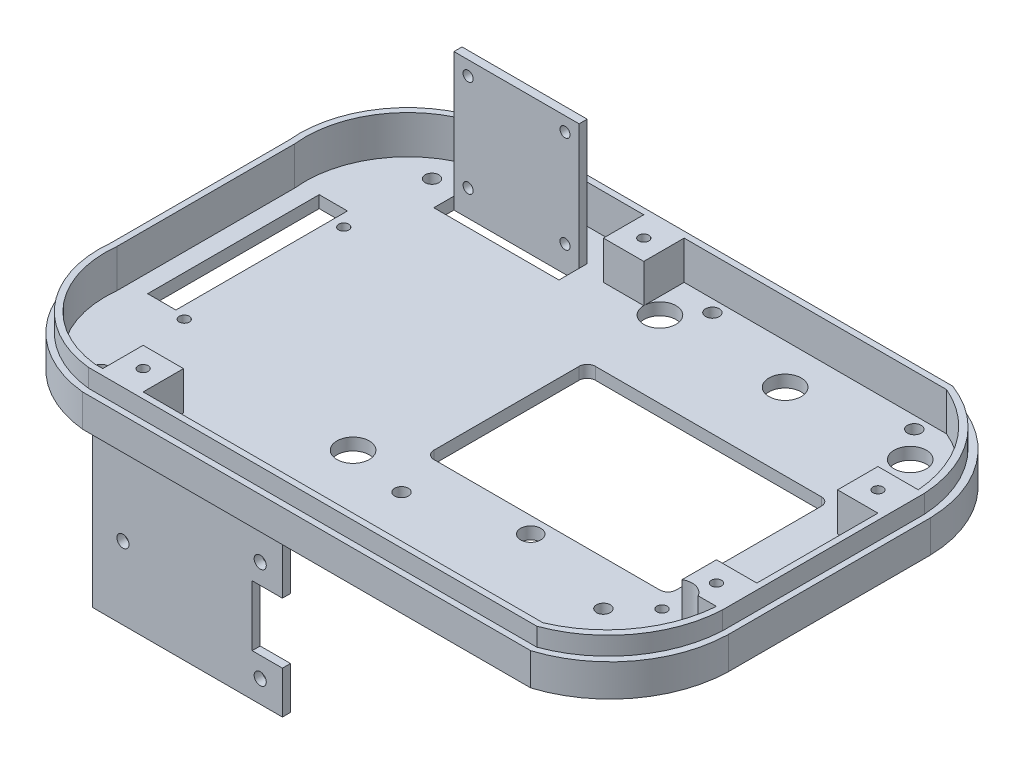
from build123d import *

# Parameters (mm, degrees)
BOSS_EXTRUDE1_DEPTH            = 86.5
SKETCH2_W                      = 200.99999999999994
SKETCH2_H                      = 100.00000000000001
CUT_EXTRUDE1_DEPTH             = 35
CUT_EXTRUDE2_DEPTH             = 49.5
CUT_EXTRUDE3_DEPTH             = 48.5
CUT_EXTRUDE4_DEPTH             = 49.5
SKETCH12_W                     = 54.00000000000001
SKETCH12_H                     = 20
CUT_EXTRUDE5_DEPTH             = 3
SKETCH19_W                     = 207
SKETCH19_H                     = 106
SKETCH19_W_2                   = 204
SKETCH19_H_2                   = 103
CUT_EXTRUDE10_DEPTH            = 30
SKETCH20_W                     = 204
SKETCH20_H                     = 103
SKETCH20_W_2                   = 200.99999999999994
SKETCH20_H_2                   = 100.00000000000001
CUT_EXTRUDE11_DEPTH            = 25.5
BOSS_EXTRUDE4_DEPTH            = 9.5
BOSS_EXTRUDE6_DEPTH            = 9.5
CUT_EXTRUDE20_DEPTH            = 126.99007897449711
FILLET2_R                      = 2
M3_CLEARANCE_HOLE1_D           = 3.4
CUT_EXTRUDE25_DEPTH            = 126.99007897449711
BOSS_EXTRUDE7_DEPTH            = 3
BOSS_EXTRUDE8_DEPTH            = 5
BOSS_EXTRUDE9_DEPTH            = 9.5
SKETCH71_W                     = 21.000000000000057
SKETCH71_H                     = 27.99999999999999
CUT_EXTRUDE26_DEPTH            = 126.99007897449708
BOSS_EXTRUDE10_DEPTH           = 3
BOSS_EXTRUDE11_DEPTH           = 5
BOSS_EXTRUDE12_DEPTH           = 9.5
CUT_EXTRUDE28_DEPTH            = 126.99007897449708
CUT_EXTRUDE28_DEPTH_BACK       = 126.99007897449708
SKETCH76_W                     = 54.99999999999997
SKETCH76_H                     = 15
BOSS_EXTRUDE16_START           = -2
BOSS_EXTRUDE16_DEPTH           = 2
BOSS_EXTRUDE19_DEPTH           = 59
CUT_EXTRUDE31_DEPTH            = 131.3926761746994
SKETCH102_W                    = 10.000000000000004
SKETCH102_H                    = 10.000000000000007
BOSS_EXTRUDE22_DEPTH           = 9.5
CUT_EXTRUDE33_DEPTH            = 53
CUT_EXTRUDE33_DEPTH_BACK       = 119.30000000000004
SKETCH108_W                    = 60.521320783260805
SKETCH108_H                    = 107.41941148005114
M3X0_5_TAPPED_HOLE6_D          = 2.5
M3X0_5_TAPPED_HOLE6_DEPTH      = 2
M3X0_5_TAPPED_HOLE6_TIP        = 0.7510757737844503
BOSS_EXTRUDE26_DEPTH           = 3
BOSS_EXTRUDE28_DEPTH           = 9.5
CUT_EXTRUDE39_DEPTH            = 117.66833332142879
CUT_EXTRUDE39_DEPTH_BACK       = 22.000000000000007
SKETCH128_W                    = 25.45272173772948
SKETCH128_H                    = 30.999999999999996
CUT_EXTRUDE40_DEPTH            = 26.000000000000018
CUT_EXTRUDE40_DEPTH_BACK       = 24.000000000000007
BOSS_EXTRUDE29_START           = -3
BOSS_EXTRUDE29_DEPTH           = 3
BOSS_EXTRUDE30_START           = -3
BOSS_EXTRUDE30_DEPTH           = 3
M3X0_5_TAPPED_HOLE8_D          = 2.5
M3X0_5_TAPPED_HOLE8_DEPTH      = 2
M3X0_5_TAPPED_HOLE8_TIP        = 0.7510757737844503
SKETCH134_W                    = 10
SKETCH134_H                    = 10.000000000000007
BOSS_EXTRUDE31_DEPTH           = 9.5
BOSS_EXTRUDE33_DEPTH           = 9.5
BOSS_EXTRUDE35_DEPTH           = 5
CUT_EXTRUDE41_START            = -9.5
SKETCH140_W                    = 9.999999999999996
SKETCH140_H                    = 10.000000000000007
SKETCH140_W_2                  = 10
CUT_EXTRUDE41_DEPTH            = 9.5
SKETCH142_W                    = 10
SKETCH142_H                    = 10.000000000000007
BOSS_EXTRUDE37_DEPTH           = 9.5
BOSS_EXTRUDE38_DEPTH           = 57
BOSS_EXTRUDE40_DEPTH           = 31
F_2_5MM_DOWEL_HOLE1_D          = 2.5
F_2_5MM_DOWEL_HOLE1_DEPTH      = 4
F_2_5MM_DOWEL_HOLE1_TIP        = 0.7510757737844503
SKETCH148_W                    = 31
SKETCH148_H                    = 5
CUT_EXTRUDE42_DEPTH            = 31
F_3_0MM_DOWEL_HOLE1_D          = 3
F_3_0MM_DOWEL_HOLE1_DEPTH      = 4
F_3_0MM_DOWEL_HOLE1_TIP        = 0.9012909285413404
CUT_EXTRUDE43_DEPTH            = 57
M3X0_5_TAPPED_HOLE9_D          = 2.5
M3X0_5_TAPPED_HOLE9_DEPTH      = 2
M3X0_5_TAPPED_HOLE9_TIP        = 0.7510757737844503
CUT_EXTRUDE44_DEPTH            = 57
M3_CLEARANCE_HOLE2_D           = 3.4
F_8_0MM_DOWEL_HOLE1_D          = 8
F_8_0MM_DOWEL_HOLE2_AT_2_COUNT = 2
F_8_0MM_DOWEL_HOLE2_AT_2_PITCH = 79.99999999999999
SKETCH165_R                    = 4.000000000000005
CUT_EXTRUDE45_DEPTH            = 10
F_5_0MM_DOWEL_HOLE1_D          = 5
F_5_0MM_DOWEL_HOLE1_DEPTH      = 12.5
F_5_0MM_DOWEL_HOLE1_TIP        = 1.5021515475689007


with BuildPart() as part:
    # Sketch1 → Boss-Extrude1 (new body)
    with BuildSketch(Plane(origin=(0, 0, 0), x_dir=(1, 0, 0), z_dir=(0, 1, 0))):
        Polygon((-103.49999999999997, 52.99999999999999), (103.50000000000003, 52.99999999999999), (103.50000000000006, -53.00000000000001), (-103.49999999999997, -53.00000000000001), align=None)
    extrude(amount=BOSS_EXTRUDE1_DEPTH)

    # Sketch2 → Cut-Extrude1 (cut)
    with BuildSketch(Plane(origin=(0, 86.5, 0), x_dir=(1, 0, 0), z_dir=(0, 1, 0))):
        Rectangle(SKETCH2_W, SKETCH2_H)
    extrude(amount=-CUT_EXTRUDE1_DEPTH, mode=Mode.SUBTRACT)

    # Sketch4 → Cut-Extrude2 (cut)
    with BuildSketch(Plane(origin=(0, 51.49999999999999, 0), x_dir=(1, 0, 0), z_dir=(0, 1, 0))):
        Polygon((-100.49999999999997, 50), (-53.50000000000001, 50), (-53.49999999999999, -50), (-100.49999999999996, -50), align=None)
    extrude(amount=-CUT_EXTRUDE2_DEPTH, mode=Mode.SUBTRACT)

    # Sketch8 → Cut-Extrude3 (cut)
    with BuildSketch(Plane.XZ):
        Polygon((-43.49999999999997, 53.00000000000001), (103.50000000000007, 53.00000000000001), (103.50000000000004, -52.99999999999999), (-43.49999999999996, -52.99999999999999), align=None)
    extrude(amount=-CUT_EXTRUDE3_DEPTH, mode=Mode.SUBTRACT)

    # Sketch11 → Cut-Extrude4 (cut)
    with BuildSketch(Plane(origin=(0, 51.49999999999999, 0), x_dir=(1, 0, 0), z_dir=(0, 1, 0))):
        Polygon((-53.50000000000001, 50), (-48.50000000000001, 50), (-48.49999999999999, -50), (-53.50000000000001, -50), align=None)
    extrude(amount=-CUT_EXTRUDE4_DEPTH, mode=Mode.SUBTRACT)

    # Sketch12 → Cut-Extrude5 (cut)
    with BuildSketch(Plane(origin=(0, 0, -52.99999999999999), x_dir=(-1, 0, 0), z_dir=(0, 0, -1))):
        with Locations((73.49999999999997, 13)):
            Rectangle(SKETCH12_W, SKETCH12_H)
    extrude(amount=-CUT_EXTRUDE5_DEPTH, mode=Mode.SUBTRACT)

    # Sketch19 → Cut-Extrude10 (cut)
    with BuildSketch(Plane(origin=(0, 86.5, 0), x_dir=(1, 0, 0), z_dir=(0, 1, 0))):
        Rectangle(SKETCH19_W, SKETCH19_H)
        Rectangle(SKETCH19_W_2, SKETCH19_H_2, mode=Mode.SUBTRACT)
    extrude(amount=-CUT_EXTRUDE10_DEPTH, mode=Mode.SUBTRACT)

    # Sketch20 → Cut-Extrude11 (cut)
    with BuildSketch(Plane(origin=(0, 86.5, 0), x_dir=(1, 0, 0), z_dir=(0, 1, 0))):
        Rectangle(SKETCH20_W, SKETCH20_H)
        Rectangle(SKETCH20_W_2, SKETCH20_H_2, mode=Mode.SUBTRACT)
    extrude(amount=-CUT_EXTRUDE11_DEPTH, mode=Mode.SUBTRACT)

    # Sketch24 → Boss-Extrude4 (add)
    with BuildSketch(Plane(origin=(0, 51.49999999999999, 0), x_dir=(1, 0, 0), z_dir=(0, 1, 0))):
        Polygon((100.49999999999999, 25.000000000000007), (90.5, 25), (90.49999999999999, 15.000000000000002), (100.49999999999999, 15.000000000000004), align=None)
    extrude(amount=BOSS_EXTRUDE4_DEPTH)

    # Sketch27 → Boss-Extrude6 (add)
    with BuildSketch(Plane(origin=(0, 51.49999999999999, 0), x_dir=(1, 0, 0), z_dir=(0, 1, 0))):
        Polygon((100.49999999999997, -15.000000000000004), (90.49999999999999, -15.000000000000005), (90.5, -25.000000000000004), (100.49999999999997, -25), align=None)
    extrude(amount=BOSS_EXTRUDE6_DEPTH)

    # Sketch53 → Cut-Extrude20 (cut, through all)
    with BuildSketch(Plane.XZ.offset(-48.5)):
        Polygon((22.49999999999997, 19.00000000000001), (82.49999999999996, 19.00000000000001), (82.49999999999996, -20.99999999999999), (22.499999999999975, -20.99999999999999), align=None)
    extrude(amount=-CUT_EXTRUDE20_DEPTH, mode=Mode.SUBTRACT)

    # Fillet2
    fillet2_edges = [part.edges().sort_by_distance(p)[0] for p in [
        (82.49999999999996, 50, 19.00000000000001),
        (82.49999999999996, 50, -20.99999999999999),
        (22.499999999999975, 50, -20.99999999999999),
        (22.49999999999997, 50, 19.00000000000001),
    ]]
    fillet(fillet2_edges, radius=FILLET2_R)

    # M3 Clearance Hole1 (through all)
    with Locations(Plane(origin=(77.5, 48.5, 30), x_dir=(0, 0, -1), z_dir=(0, -1, 0))):
        with Locations((0, 0), (0, -50), (77, -50), (77, 0)):
            Hole(M3_CLEARANCE_HOLE1_D / 2)

    # Sketch66 → Cut-Extrude25 (cut, through all)
    with BuildSketch(Plane(origin=(0, 48.5, 0), x_dir=(1, 0, 0), z_dir=(0, 1, 0))):
        Polygon((103.50000000000006, -25.000000000000004), (82.49999999999999, -25.000000000000007), (82.49999999999997, -53.00000000000001), (103.50000000000006, -53.00000000000001), align=None)
    extrude(amount=CUT_EXTRUDE25_DEPTH, mode=Mode.SUBTRACT)

    # Sketch68 → Boss-Extrude7 (add)
    with BuildSketch(Plane(origin=(0, 48.5, 0), x_dir=(1, 0, 0), z_dir=(0, 1, 0))):
        with BuildLine():
            Line((103.50000000000006, -25.000000000000004), (82.49999999999999, -25.000000000000007))
            Line((82.49999999999999, -25.000000000000007), (82.49999999999997, -53.00000000000001))
            ThreePointArc((82.49999999999997, -53.00000000000001), (97.50520776831563, -42.37890582623673), (103.50000000000006, -25.000000000000004))
        make_face()
    extrude(amount=BOSS_EXTRUDE7_DEPTH)

    # Sketch69 → Boss-Extrude8 (add)
    with BuildSketch(Plane(origin=(0, 51.49999999999999, 0), x_dir=(1, 0, 0), z_dir=(0, 1, 0))):
        with BuildLine():
            Line((103.50000000000006, -25.000000000000004), (102.00000000000006, -25.000000000000004))
            ThreePointArc((102.00000000000006, -25.000000000000004), (96.24183965338148, -41.1873914430543), (82.49999999999997, -51.50000000000001))
            Line((82.49999999999997, -51.50000000000001), (82.49999999999997, -53.00000000000001))
            ThreePointArc((82.49999999999997, -53.00000000000001), (97.50520776831564, -42.378905826236746), (103.50000000000006, -25.000000000000004))
        make_face()
    extrude(amount=BOSS_EXTRUDE8_DEPTH)

    # Sketch70 → Boss-Extrude9 (add)
    with BuildSketch(Plane(origin=(0, 51.49999999999999, 0), x_dir=(1, 0, 0), z_dir=(0, 1, 0))):
        with BuildLine():
            Line((102.00000000000006, -25.000000000000004), (100.50704002549185, -25))
            ThreePointArc((100.50704002549185, -25), (95.01246001639046, -40.02742492370709), (82.49999999999997, -49.99999999999999))
            Line((82.49999999999997, -49.99999999999999), (82.49999999999997, -51.50000000000001))
            ThreePointArc((82.49999999999997, -51.50000000000001), (96.24183965338145, -41.18739144305428), (102.00000000000006, -25.000000000000004))
        make_face()
    extrude(amount=BOSS_EXTRUDE9_DEPTH)

    # Sketch71 → Cut-Extrude26 (cut, through all)
    with BuildSketch(Plane(origin=(0, 48.5, 0), x_dir=(1, 0, 0), z_dir=(0, 1, 0))):
        with Locations((93.00000000000001, 39)):
            Rectangle(SKETCH71_W, SKETCH71_H)
    extrude(amount=CUT_EXTRUDE26_DEPTH, mode=Mode.SUBTRACT)

    # Sketch72 → Boss-Extrude10 (add)
    with BuildSketch(Plane(origin=(0, 48.5, 0), x_dir=(1, 0, 0), z_dir=(0, 1, 0))):
        with BuildLine():
            Line((82.49999999999999, 52.99999999999999), (82.49999999999999, 25.000000000000004))
            Line((82.49999999999999, 25.000000000000004), (103.50000000000006, 25.000000000000004))
            ThreePointArc((103.50000000000006, 25.000000000000004), (97.50520776831563, 42.37890582623672), (82.49999999999999, 52.99999999999999))
        make_face()
    extrude(amount=BOSS_EXTRUDE10_DEPTH)

    # Sketch73 → Boss-Extrude11 (add)
    with BuildSketch(Plane(origin=(0, 51.49999999999999, 0), x_dir=(1, 0, 0), z_dir=(0, 1, 0))):
        with BuildLine():
            Line((82.49999999999999, 52.99999999999999), (82.49999999999999, 51.5))
            ThreePointArc((82.49999999999999, 51.5), (96.19969008066016, 41.15637571973106), (102.00000000000006, 25.000000000000004))
            Line((102.00000000000006, 25.000000000000004), (103.50000000000006, 25.000000000000004))
            ThreePointArc((103.50000000000006, 25.000000000000004), (97.50520776831563, 42.37890582623672), (82.49999999999999, 52.99999999999999))
        make_face()
    extrude(amount=BOSS_EXTRUDE11_DEPTH)

    # Sketch74 → Boss-Extrude12 (add)
    with BuildSketch(Plane(origin=(0, 51.49999999999999, 0), x_dir=(1, 0, 0), z_dir=(0, 1, 0))):
        with BuildLine():
            Line((82.49999999999997, 51.49999999999999), (82.49999999999999, 50))
            ThreePointArc((82.49999999999999, 50), (94.96903162969512, 39.99770277338048), (100.50000000000006, 25.000000000000004))
            Line((100.50000000000006, 25.000000000000004), (102.00000000000006, 25.000000000000004))
            ThreePointArc((102.00000000000006, 25.000000000000004), (96.19669921807576, 41.1541748963199), (82.49999999999997, 51.49999999999999))
        make_face()
    extrude(amount=BOSS_EXTRUDE12_DEPTH)

    # Sketch76 → Cut-Extrude28 (cut, two sides: drawn at the far end of the back side and taken through both)
    with BuildSketch(Plane(origin=(0, 48.5, 0), x_dir=(1, 0, 0), z_dir=(0, 1, 0)).offset(-CUT_EXTRUDE28_DEPTH_BACK)):
        with Locations((-75.99999999999999, -45.50000000000001)):
            Rectangle(SKETCH76_W, SKETCH76_H)
    extrude(amount=CUT_EXTRUDE28_DEPTH + CUT_EXTRUDE28_DEPTH_BACK, mode=Mode.SUBTRACT)

    # Sketch85 → Boss-Extrude16 (add)
    with BuildSketch(Plane.XZ.offset(BOSS_EXTRUDE16_START)):
        Polygon((-103.49999999999997, 38.00000000000001), (-83.49999999999996, 48.00000000000001), (-48.5, 53.00000000000001), (-48.5, 38.00000000000001), align=None)
    extrude(amount=BOSS_EXTRUDE16_DEPTH)

    # Sketch95 → Boss-Extrude19 (add)
    with BuildSketch(Plane(origin=(0, 1.999999999999988, 0), x_dir=(1, 0, 0), z_dir=(0, 1, 0))):
        Polygon((-48.5, -53.00000000000001), (-83.49999999999996, -48.00000000000001), (-83.49999999999996, -45.00000000000001), (-48.5, -50), align=None)
    extrude(amount=BOSS_EXTRUDE19_DEPTH)

    # Sketch96 → Cut-Extrude31 (cut, through all)
    with BuildSketch(Plane(origin=(0, 1.999999999999988, 0), x_dir=(1, 0, 0), z_dir=(0, 1, 0))):
        Polygon((-83.49999999999996, -45.00000000000001), (-83.49999999999996, -48.00000000000001), (-103.49999999999997, -38.00000000000001), (-103.49999999999997, -35), align=None)
    extrude(amount=CUT_EXTRUDE31_DEPTH, mode=Mode.SUBTRACT)

    # Sketch102 → Boss-Extrude22 (add)
    with BuildSketch(Plane(origin=(0, 51.49999999999999, 0), x_dir=(1, 0, 0), z_dir=(0, 1, 0))):
        with Locations((-33.5, -45)):
            Rectangle(SKETCH102_W, SKETCH102_H)
    extrude(amount=BOSS_EXTRUDE22_DEPTH)

    # Sketch108 → Cut-Extrude33 (cut, two sides: drawn at the far end of the back side and taken through both)
    with BuildSketch(Plane.XZ.offset(-CUT_EXTRUDE33_DEPTH_BACK)):
        with Locations((-73.76066039163035, 0.7097057400255764)):
            Rectangle(SKETCH108_W, SKETCH108_H)
    extrude(amount=CUT_EXTRUDE33_DEPTH + CUT_EXTRUDE33_DEPTH_BACK, mode=Mode.SUBTRACT)

    # M3x0.5 Tapped Hole6
    with Locations(Plane(origin=(84.82, 51.5, 22.8), x_dir=(0, 0, 1), z_dir=(0, 1, 0))):
        with Locations((0, 0), (-45.5, 0)):
            Hole(M3X0_5_TAPPED_HOLE6_D / 2, depth=M3X0_5_TAPPED_HOLE6_DEPTH)
            with Locations((0, 0, -(M3X0_5_TAPPED_HOLE6_DEPTH + M3X0_5_TAPPED_HOLE6_TIP / 2))):  # 118° drill point
                Cone(0, M3X0_5_TAPPED_HOLE6_D / 2, M3X0_5_TAPPED_HOLE6_TIP, mode=Mode.SUBTRACT)

    # Sketch121 → Boss-Extrude26 (add)
    with BuildSketch(Plane.XZ.offset(-48.5)):
        Polygon((-53.95272173772948, -21.999999999999996), (-43.45272173772946, -21.999999999999996), (-43.452721737729476, 21.999999999999996), (-53.95272173772949, 22.000000000000004), align=None)
    extrude(amount=-BOSS_EXTRUDE26_DEPTH)

    # Sketch123 → Boss-Extrude28 (add)
    with BuildSketch(Plane(origin=(0, 51.49999999999999, 0), x_dir=(1, 0, 0), z_dir=(0, 1, 0))):
        Polygon((-38.50000000000001, 50), (-28.49999999999999, 50), (-28.499999999999996, 40.00000000000001), (-38.5, 40), align=None)
    extrude(amount=BOSS_EXTRUDE28_DEPTH)

    # Sketch128 → Cut-Extrude39 (cut, two sides: drawn at the far end of the back side and taken through both)
    with BuildSketch(Plane(origin=(0, 51.49999999999999, 0), x_dir=(1, 0, 0), z_dir=(0, 1, 0)).offset(-CUT_EXTRUDE39_DEPTH_BACK)):
        with Locations((-41.22636086886474, 37.49999999999999)):
            Rectangle(SKETCH128_W, SKETCH128_H)
    extrude(amount=CUT_EXTRUDE39_DEPTH + CUT_EXTRUDE39_DEPTH_BACK, mode=Mode.SUBTRACT)

    # Sketch129 → Cut-Extrude40 (cut, two sides: drawn at the far end of the back side and taken through both)
    with BuildSketch(Plane(origin=(0, 51.49999999999999, 0), x_dir=(1, 0, 0), z_dir=(0, 1, 0)).offset(-CUT_EXTRUDE40_DEPTH_BACK)):
        Polygon((-53.95272173772949, -22.000000000000004), (-28.499999999999996, -22), (-28.499999999999996, -53.00000000000001), (-53.95272173772948, -53.00000000000001), align=None)
    extrude(amount=CUT_EXTRUDE40_DEPTH + CUT_EXTRUDE40_DEPTH_BACK, mode=Mode.SUBTRACT)

    # Sketch130 → Boss-Extrude29 (add)
    with BuildSketch(Plane.XZ.offset(-48.5).offset(BOSS_EXTRUDE29_START)):
        with BuildLine():
            Line((-28.499999999999996, -52.99999999999999), (-28.499999999999996, -21.999999999999996))
            Line((-28.499999999999996, -21.999999999999996), (-53.95272173772948, -21.999999999999996))
            ThreePointArc((-53.95272173772948, -21.999999999999996), (-47.63988467825608, -42.76585925415292), (-28.499999999999996, -52.99999999999999))
        make_face()
    extrude(amount=BOSS_EXTRUDE29_DEPTH)

    # Sketch131 → Boss-Extrude30 (add)
    with BuildSketch(Plane.XZ.offset(-48.5).offset(BOSS_EXTRUDE30_START)):
        with BuildLine():
            Line((-53.95272173772949, 22.000000000000004), (-28.499999999999996, 22))
            Line((-28.499999999999996, 22), (-28.499999999999996, 53.00000000000001))
            ThreePointArc((-28.499999999999996, 53.00000000000001), (-47.63988467825607, 42.765859254152915), (-53.95272173772949, 22.000000000000004))
        make_face()
    extrude(amount=BOSS_EXTRUDE30_DEPTH)

    # M3x0.5 Tapped Hole8
    with Locations(Plane(origin=(-36.51, 51.5, 19.8), x_dir=(0, 0, 1), z_dir=(0, 1, 0))):
        with Locations((0, 0), (-39.5, 0)):
            Hole(M3X0_5_TAPPED_HOLE8_D / 2, depth=M3X0_5_TAPPED_HOLE8_DEPTH)
            with Locations((0, 0, -(M3X0_5_TAPPED_HOLE8_DEPTH + M3X0_5_TAPPED_HOLE8_TIP / 2))):  # 118° drill point
                Cone(0, M3X0_5_TAPPED_HOLE8_D / 2, M3X0_5_TAPPED_HOLE8_TIP, mode=Mode.SUBTRACT)

    # Sketch134 → Boss-Extrude31 (add)
    with BuildSketch(Plane(origin=(0, 51.49999999999999, 0), x_dir=(1, 0, 0), z_dir=(0, 1, 0))):
        Polygon((-23.499999999999993, 50), (-13.499999999999998, 50), (-13.499999999999996, 40), (-23.499999999999996, 40), align=None)
        with Locations((-18.499999999999996, -45)):
            Rectangle(SKETCH134_W, SKETCH134_H)
    extrude(amount=BOSS_EXTRUDE31_DEPTH)

    # Sketch135 → Boss-Extrude33 (add)
    with BuildSketch(Plane(origin=(0, 51.49999999999999, 0), x_dir=(1, 0, 0), z_dir=(0, 1, 0))):
        with BuildLine():
            Line((-50.95272173772949, 21.999999999999996), (-50.95272173772948, -22.000000000000004))
            ThreePointArc((-50.95272173772948, -22.000000000000004), (-45.51859758066482, -40.64469568318244), (-28.499999999999996, -50))
            Line((-28.499999999999996, -50), (-28.499999999999982, -51.50000000000001))
            ThreePointArc((-28.499999999999982, -51.50000000000001), (-46.58601091386788, -41.71077109975819), (-52.45272173772949, -22.000000000000004))
            Line((-52.45272173772949, -22.000000000000004), (-52.45272173772949, -6.682311808588085))
            Line((-52.45272173772949, -6.682311808588085), (-52.45272173772948, -5.855213359679426))
            Line((-52.45272173772948, -5.855213359679426), (-52.45272173772949, 21.999999999999996))
            ThreePointArc((-52.45272173772949, 21.999999999999996), (-46.57714764865434, 41.70357451245826), (-28.499999999999996, 51.5))
            Line((-28.499999999999996, 51.5), (-28.499999999999996, 50))
            ThreePointArc((-28.499999999999996, 50), (-45.51859758066485, 40.64469568318246), (-50.95272173772949, 21.999999999999996))
        make_face()
    extrude(amount=BOSS_EXTRUDE33_DEPTH)

    # Sketch139 → Boss-Extrude35 (add)
    with BuildSketch(Plane(origin=(0, 51.49999999999999, 0), x_dir=(1, 0, 0), z_dir=(0, 1, 0))):
        with BuildLine():
            ThreePointArc((-28.499999999999996, -51.50000000000001), (-46.58601091386788, -41.71077109975819), (-52.45272173772948, -21.999999999999993))
            Line((-52.45272173772948, -21.999999999999993), (-52.45272173772949, 21.999999999999996))
            ThreePointArc((-52.45272173772949, 21.999999999999996), (-46.57714764865434, 41.70357451245825), (-28.499999999999996, 51.49999999999999))
            Line((-28.499999999999996, 51.49999999999999), (-28.499999999999996, 52.99999999999999))
            ThreePointArc((-28.499999999999996, 52.99999999999999), (-47.63988467825608, 42.76585925415292), (-53.95272173772948, 21.999999999999996))
            Line((-53.95272173772948, 21.999999999999996), (-53.95272173772949, -22.000000000000004))
            ThreePointArc((-53.95272173772949, -22.000000000000004), (-47.63988467825607, -42.76585925415291), (-28.499999999999996, -53.00000000000001))
            Line((-28.499999999999996, -53.00000000000001), (-28.499999999999996, -51.50000000000001))
        make_face()
    extrude(amount=BOSS_EXTRUDE35_DEPTH)

    # Sketch140 → Cut-Extrude41 (cut)
    with BuildSketch(Plane(origin=(0, 61, 0), x_dir=(1, 0, 0), z_dir=(0, 1, 0)).offset(CUT_EXTRUDE41_START)):
        with Locations((-18.499999999999993, 45)):
            Rectangle(SKETCH140_W, SKETCH140_H)
        with Locations((-18.499999999999996, -45)):
            Rectangle(SKETCH140_W_2, SKETCH140_H)
    extrude(amount=CUT_EXTRUDE41_DEPTH, mode=Mode.SUBTRACT)

    # Sketch142 → Boss-Extrude37 (add)
    with BuildSketch(Plane(origin=(0, 51.49999999999999, 0), x_dir=(1, 0, 0), z_dir=(0, 1, 0))):
        Polygon((7.499999999999979, 50), (17.49999999999999, 50), (17.49999999999999, 40), (7.499999999999988, 40), align=None)
        with Locations((-21.50000000000001, -45)):
            Rectangle(SKETCH142_W, SKETCH142_H)
    extrude(amount=BOSS_EXTRUDE37_DEPTH)

    # Sketch143 → Boss-Extrude38 (add)
    with BuildSketch(Plane.XZ.offset(-48.5)):
        Polygon((-46.00000000000002, 33), (0.999999999999987, 33), (0.9999999999999883, 31), (-46.000000000000014, 31), align=None)
    extrude(amount=BOSS_EXTRUDE38_DEPTH)

    # Sketch145 → Boss-Extrude40 (add)
    with BuildSketch(Plane(origin=(0, 51.49999999999999, 0), x_dir=(1, 0, 0), z_dir=(0, 1, 0))):
        Polygon((-29.510000000000016, 42), (1.489999999999984, 42), (1.4899999999999844, 40.00000000000001), (-29.510000000000016, 40), align=None)
    extrude(amount=BOSS_EXTRUDE40_DEPTH)

    # Ø2.5mm Dowel Hole1
    with Locations(Plane(origin=(-26.01, 79, -40), x_dir=(1, 0, 0), z_dir=(0, 0, 1))):
        with Locations((0, 0), (24, 0), (0, -24), (24, -24)):
            Hole(F_2_5MM_DOWEL_HOLE1_D / 2, depth=F_2_5MM_DOWEL_HOLE1_DEPTH)
            with Locations((0, 0, -(F_2_5MM_DOWEL_HOLE1_DEPTH + F_2_5MM_DOWEL_HOLE1_TIP / 2))):  # 118° drill point
                Cone(0, F_2_5MM_DOWEL_HOLE1_D / 2, F_2_5MM_DOWEL_HOLE1_TIP, mode=Mode.SUBTRACT)

    # Sketch148 → Cut-Extrude42 (cut)
    with BuildSketch(Plane(origin=(0, 51.49999999999999, 0), x_dir=(1, 0, 0), z_dir=(0, 1, 0))):
        with Locations((-14.010000000000016, 37.5)):
            Rectangle(SKETCH148_W, SKETCH148_H)
    extrude(amount=-CUT_EXTRUDE42_DEPTH, mode=Mode.SUBTRACT)

    # Ø3.0mm Dowel Hole1
    with Locations(Plane(origin=(-4.5, -3, 31), x_dir=(-1, 0, 0), z_dir=(0, 0, -1))):
        with Locations((0, 0), (0, 25), (34, 12.5)):
            Hole(F_3_0MM_DOWEL_HOLE1_D / 2, depth=F_3_0MM_DOWEL_HOLE1_DEPTH)
            with Locations((0, 0, -(F_3_0MM_DOWEL_HOLE1_DEPTH + F_3_0MM_DOWEL_HOLE1_TIP / 2))):  # 118° drill point
                Cone(0, F_3_0MM_DOWEL_HOLE1_D / 2, F_3_0MM_DOWEL_HOLE1_TIP, mode=Mode.SUBTRACT)

    # Sketch156 → Cut-Extrude43 (cut)
    with BuildSketch(Plane(origin=(0, 0, 31), x_dir=(-1, 0, 0), z_dir=(0, 0, -1))):
        Polygon((-0.9999999999999883, 1.9999999999999982), (6.500000000000011, 1.9999999999999991), (6.500000000000011, 16.999999999999996), (-0.9999999999999883, 16.999999999999996), align=None)
    extrude(amount=-CUT_EXTRUDE43_DEPTH, mode=Mode.SUBTRACT)

    # M3x0.5 Tapped Hole9
    with Locations(Plane(origin=(12.5, 61, -45), x_dir=(0, 0, 1), z_dir=(0, 1, 0))):
        with Locations((0, 0), (90, -34), (65, 83), (25, 83)):
            Hole(M3X0_5_TAPPED_HOLE9_D / 2, depth=M3X0_5_TAPPED_HOLE9_DEPTH)
            with Locations((0, 0, -(M3X0_5_TAPPED_HOLE9_DEPTH + M3X0_5_TAPPED_HOLE9_TIP / 2))):  # 118° drill point
                Cone(0, M3X0_5_TAPPED_HOLE9_D / 2, M3X0_5_TAPPED_HOLE9_TIP, mode=Mode.SUBTRACT)

    # Sketch158 → Cut-Extrude44 (cut)
    with BuildSketch(Plane(origin=(0, 51.49999999999999, 0), x_dir=(1, 0, 0), z_dir=(0, 1, 0))):
        Polygon((-46.51000000000001, 23.61959970909311), (-39.51000000000001, 23.619599709093112), (-39.510000000000005, -18.87341891990957), (-46.51, -18.873418919909568), align=None)
    extrude(amount=-CUT_EXTRUDE44_DEPTH, mode=Mode.SUBTRACT)

    # M3 Clearance Hole2 (through all)
    with Locations(Plane(origin=(-35.952721738, 51.5, -41), x_dir=(0, 0, 1), z_dir=(0, 1, 0))):
        with Locations((0, 0), (82, 0)):
            Hole(M3_CLEARANCE_HOLE2_D / 2)

    # Ø8.0mm Dowel Hole1 (through all)
    with Locations(Plane(origin=(83.5, 51.5, -40), x_dir=(0, 0, 1), z_dir=(0, 1, 0))):
        with Locations((0, 0), (0, -31), (0, -62)):
            Hole(F_8_0MM_DOWEL_HOLE1_D / 2)

    # Sketch162 → Ø8.0mm Dowel Hole2 (revolve, cut)
    with BuildSketch(Plane(origin=(12.499999999999972, 51.49999999999999, 27.00000000000001), x_dir=(0, 0, 1), z_dir=(1, 0, 0))):
        Polygon((0, 0), (-1.47e-14, 59.99999999999999), (3.9999999999999907, 59.99999999999999), (3.999999999999988, -1.07e-15), align=None)
    f_8_0mm_dowel_hole2 = revolve(axis=Axis((12.499999999999972, 57.84999999999998, 27.00000000000001), (0, -1, 0)), mode=Mode.SUBTRACT)

    # Ø8.0mm Dowel Hole2 at 2: Ø8.0mm Dowel Hole2 ×2
    with Locations(*[(i * F_8_0MM_DOWEL_HOLE2_AT_2_PITCH, 0, 0) for i in range(1, F_8_0MM_DOWEL_HOLE2_AT_2_COUNT)]):
        add(f_8_0mm_dowel_hole2, mode=Mode.SUBTRACT)

    # Sketch165 → Cut-Extrude45 (cut)
    with BuildSketch(Plane(origin=(0, 61, 0), x_dir=(1, 0, 0), z_dir=(0, 1, 0))):
        with Locations(Location((92.49999999999996, -27.00000000000001, 0), (0, 0, 30))):
            Circle(SKETCH165_R)
    extrude(amount=-CUT_EXTRUDE45_DEPTH, mode=Mode.SUBTRACT)

    # Ø5.0mm Dowel Hole1
    with Locations(Plane(origin=(52.5, 51.5, 23), x_dir=(0, 0, 1), z_dir=(0, 1, 0))):
        with Locations((0, 0)):
            Hole(F_5_0MM_DOWEL_HOLE1_D / 2, depth=F_5_0MM_DOWEL_HOLE1_DEPTH)
            with Locations((0, 0, -(F_5_0MM_DOWEL_HOLE1_DEPTH + F_5_0MM_DOWEL_HOLE1_TIP / 2))):  # 118° drill point
                Cone(0, F_5_0MM_DOWEL_HOLE1_D / 2, F_5_0MM_DOWEL_HOLE1_TIP, mode=Mode.SUBTRACT)


solid = part.part
